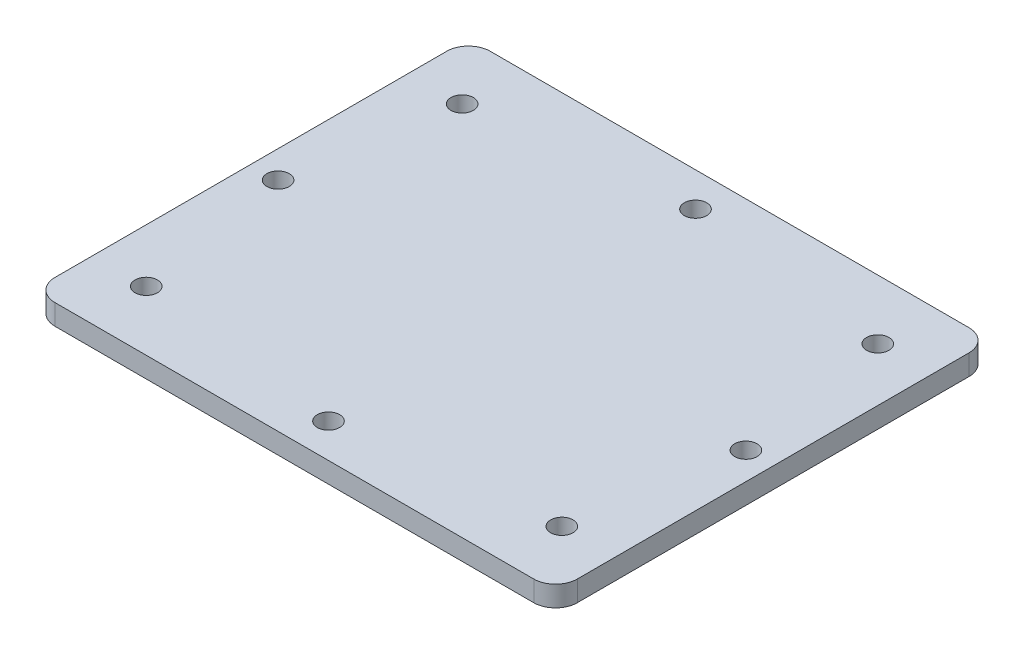
from build123d import *

# Parameters (mm, degrees)
SKETCH1_W                 = 76.2
SKETCH1_H                 = 63.5
BOSS_EXTRUDE1_DEPTH       = 1.5
FILLET1_R                 = 3.175
F_4_CLEARANCE_HOLE1_D     = 3.2639
F_4_CLEARANCE_HOLE1_DEPTH = 6.619425513
F_4_CLEARANCE_HOLE1_TIP   = 0.980574487


with BuildPart() as part:
    # Sketch1 → Boss-Extrude1 (new body, symmetric)
    with BuildSketch(Plane(origin=(0, 0, 0), x_dir=(1, 0, 0), z_dir=(0, 1, 0))):
        Rectangle(SKETCH1_W, SKETCH1_H)
    extrude(amount=BOSS_EXTRUDE1_DEPTH, both=True)

    # Fillet1
    fillet1_edges = [part.edges().sort_by_distance(p)[0] for p in [
        (38.1, 0, 31.75),
        (-38.1, 0, 31.75),
        (-38.1, 0, -31.75),
        (38.1, 0, -31.75),
    ]]
    fillet(fillet1_edges, radius=FILLET1_R)

    # #4 Clearance Hole1
    with Locations(Plane(origin=(0, 1.5, 0), x_dir=(1, 0, 0), z_dir=(0, 1, 0))):
        with Locations((-34.125, 0), (-30.315, -23.045), (0, -26.77), (30.315, -23.045), (34.125, 0), (30.315, 23.045), (0, 26.77), (-30.315, 23.045)):
            Hole(F_4_CLEARANCE_HOLE1_D / 2, depth=F_4_CLEARANCE_HOLE1_DEPTH)
            with Locations((0, 0, -(F_4_CLEARANCE_HOLE1_DEPTH + F_4_CLEARANCE_HOLE1_TIP / 2))):  # 118° drill point
                Cone(0, F_4_CLEARANCE_HOLE1_D / 2, F_4_CLEARANCE_HOLE1_TIP, mode=Mode.SUBTRACT)


solid = part.part
